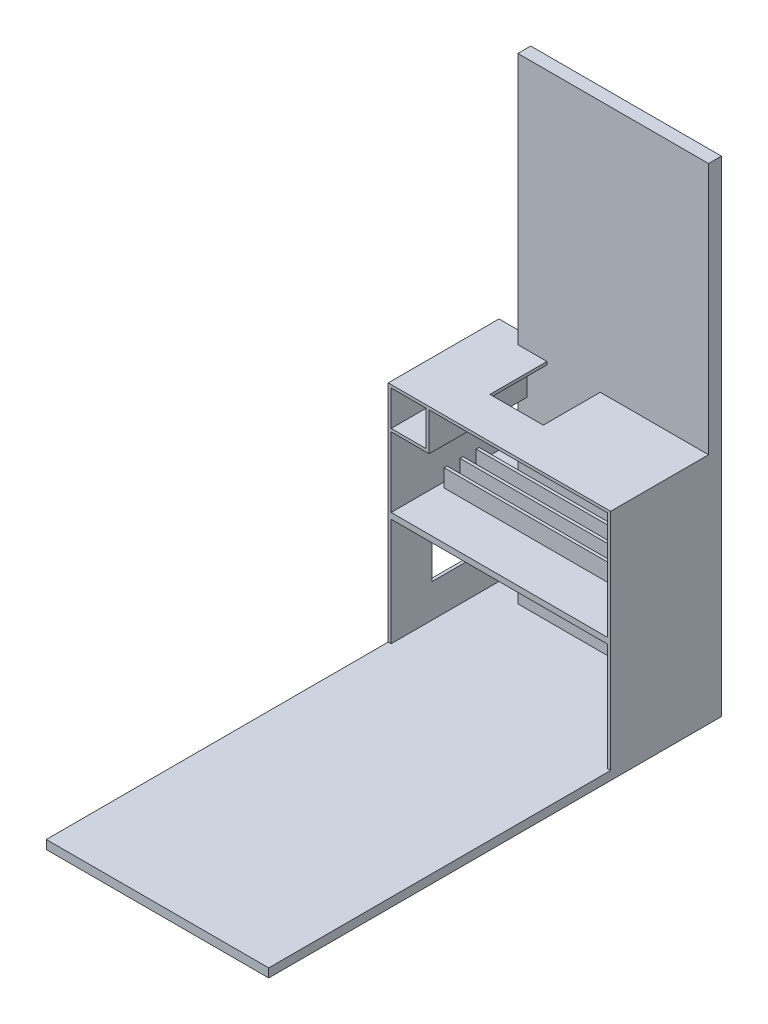
from build123d import *

# Parameters (mm, degrees)
SKETCH1_W           = 6525
SKETCH1_H           = 16410
BOSS_EXTRUDE1_DEPTH = 440
SKETCH2_W           = 7410
SKETCH2_H           = 3690
SKETCH2_W_2         = 1200
SKETCH2_H_2         = 1200
BOSS_EXTRUDE2_DEPTH = 3790
SKETCH3_W           = 1824
SKETCH3_H           = 1950
CUT_EXTRUDE1_DEPTH  = 665
SKETCH4_W           = 1950
SKETCH4_H           = 850
SKETCH4_H_2         = 1557.668186724
CUT_EXTRUDE2_DEPTH  = 736
SKETCH5_W           = 7061.635181126
SKETCH5_H           = 100
BOSS_EXTRUDE3_DEPTH = 600
LPATTERN1_COUNT     = 3
LPATTERN1_PITCH     = 550
SKETCH7_W           = 7610
SKETCH7_H           = 300
BOSS_EXTRUDE4_DEPTH = 15500


with BuildPart() as part:
    # Sketch1 → Boss-Extrude1 (new body)
    with BuildSketch(Plane(origin=(0, 0, 38431.700196057), x_dir=(-1, 0, 0), z_dir=(0, 0, -1))):
        with Locations((11259.117683291, 11712.481366586)):
            Rectangle(SKETCH1_W, SKETCH1_H)
    extrude(amount=-BOSS_EXTRUDE1_DEPTH)

    # Sketch2 → Boss-Extrude2 (add)
    with BuildSketch(Plane(origin=(0, 0, 38431.700196057), x_dir=(-1, 0, 0), z_dir=(0, 0, -1))):
        Polygon((15606.617683291, 11287.481366586), (7996.617683291, 11287.481366586), (7996.617683291, 11187.481366586), (7996.617683291, 3507.481366586), (15606.617683291, 3507.481366586), align=None)
        with Locations((11801.617683291, 5452.481366586)):
            Rectangle(SKETCH2_W, SKETCH2_H, mode=Mode.SUBTRACT)
        Polygon((8096.617683291, 7497.481366586), (8096.617683291, 11187.481366586), (14206.617683291, 11187.481366586), (14206.617683291, 9887.481366586), (15506.617683291, 9887.481366586), (15506.617683291, 7497.481366586), align=None, mode=Mode.SUBTRACT)
        with Locations((14906.617683291, 10587.481366586)):
            Rectangle(SKETCH2_W_2, SKETCH2_H_2, mode=Mode.SUBTRACT)
    extrude(amount=-BOSS_EXTRUDE2_DEPTH)

    # Sketch3 → Cut-Extrude1 (cut)
    with BuildSketch(Plane(origin=(0, 11287.481366586, 0), x_dir=(1, 0, 0), z_dir=(0, 1, 0))):
        with Locations((-12613.653311195, -39846.700196057)):
            Rectangle(SKETCH3_W, SKETCH3_H)
    extrude(amount=-CUT_EXTRUDE1_DEPTH, mode=Mode.SUBTRACT)

    # Sketch4 → Cut-Extrude2 (cut)
    with BuildSketch(Plane.ZY.offset(15606.617683291)):
        with Locations((39846.700196057, 10590.577030871)):
            Rectangle(SKETCH4_W, SKETCH4_H)
        with Locations((39846.700196057, 5530.745749443)):
            Rectangle(SKETCH4_W, SKETCH4_H_2)
    extrude(amount=-CUT_EXTRUDE2_DEPTH, mode=Mode.SUBTRACT)

    # Sketch5 → Boss-Extrude3 (add)
    with BuildSketch(Plane(origin=(0, 7497.481366586, 0), x_dir=(1, 0, 0), z_dir=(0, 1, 0))):
        with Locations((-11801.617683291, -40539.241329648)):
            Rectangle(SKETCH5_W, SKETCH5_H)
    boss_extrude3 = extrude(amount=BOSS_EXTRUDE3_DEPTH)

    # LPattern1: Boss-Extrude3 ×3
    with Locations(*[(0, 0, -i * LPATTERN1_PITCH) for i in range(1, LPATTERN1_COUNT)]):
        add(boss_extrude3)

    # Sketch7 → Boss-Extrude4 (add)
    with BuildSketch(Plane(origin=(0, 0, 38421.700196057), x_dir=(-1, 0, 0), z_dir=(0, 0, -1))):
        with Locations((11801.617683291, 3457.481366586)):
            Rectangle(SKETCH7_W, SKETCH7_H)
    extrude(amount=-BOSS_EXTRUDE4_DEPTH)


solid = part.part
